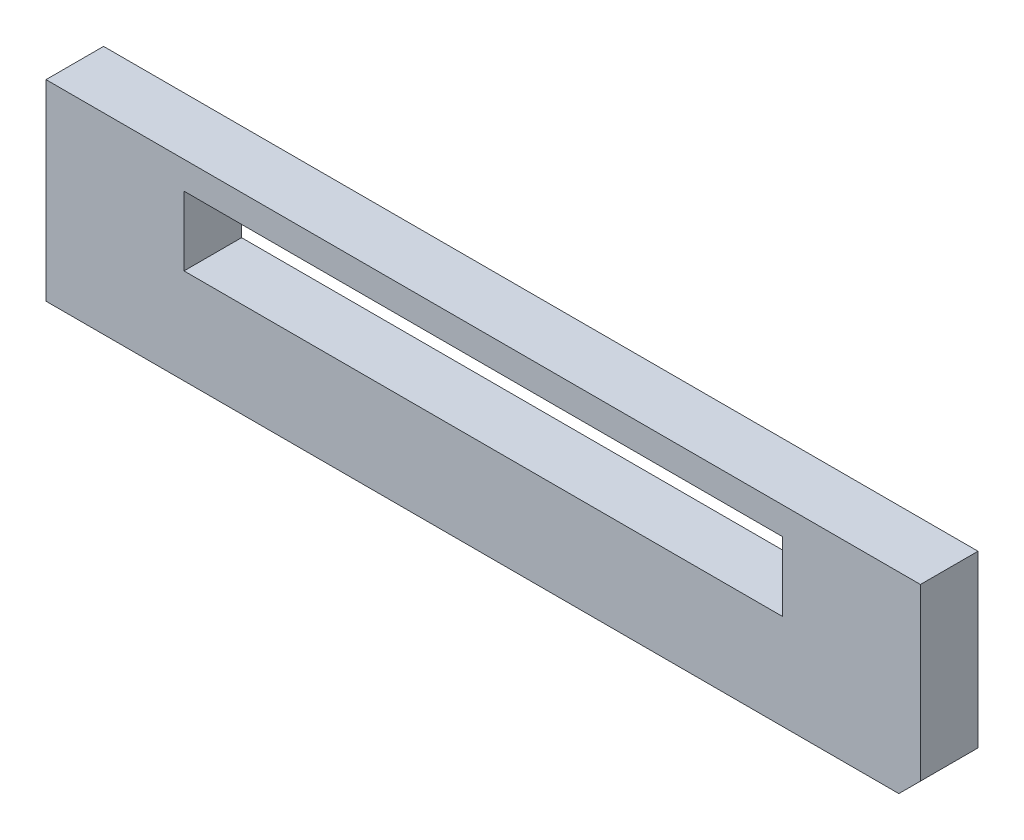
from build123d import *

# Parameters (mm, degrees)
SKETCH_1_W          = 81.1
SKETCH_1_H          = 17.8
EXTRUDE_1_DEPTH     = 5.34
CHAMFER_1_SIZE      = 2
SKETCH_2_W          = 55.5
SKETCH_2_H          = 6.409449073
CUT_EXTRUDE_1_DEPTH = 6.34


with BuildPart() as part:
    # Эскиз1 → Бобышка-Вытянуть1 (new body)
    with BuildSketch(Plane.XY):
        with Locations((40.55, 8.9)):
            Rectangle(SKETCH_1_W, SKETCH_1_H)
    extrude(amount=EXTRUDE_1_DEPTH)

    # Фаска1
    chamfer_1_edges = [part.edges().sort_by_distance(p)[0] for p in [
        (81.1, 0, 2.67),
    ]]
    chamfer(chamfer_1_edges, length=CHAMFER_1_SIZE)

    # Эскиз2 → Вырез-Вытянуть1 (cut, through all)
    with BuildSketch(Plane.XY.offset(5.34)):
        with Locations((40.55, 12.038647742)):
            Rectangle(SKETCH_2_W, SKETCH_2_H)
    extrude(amount=-CUT_EXTRUDE_1_DEPTH, mode=Mode.SUBTRACT)


solid = part.part
